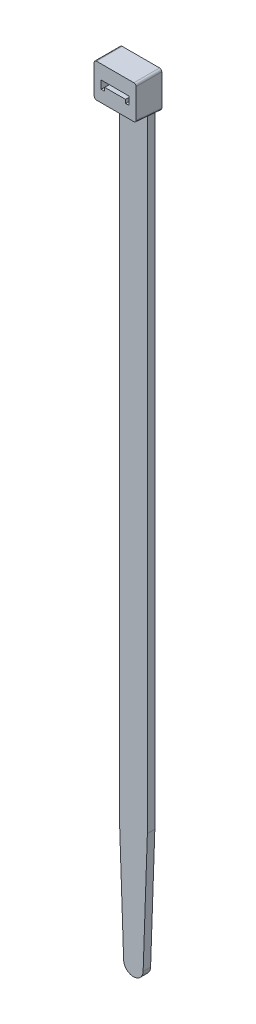
from build123d import *

# Parameters (mm, degrees)
BOSS_EXTRUDE1_DEPTH = 2.032
BOSS_EXTRUDE2_DEPTH = 5.7
CUT_EXTRUDE1_DEPTH  = 7
FILLET1_R           = 0.6


with BuildPart() as part:
    # Sketch1 → Boss-Extrude1 (new body)
    with BuildSketch(Plane.XY):
        with BuildLine():
            Line((3.81, 0), (3.81, -180.234))
            Line((3.81, -180.234), (2.654016147, -213.337046398))
            ThreePointArc((2.654016147, -213.337046398), (1.844758309, -215.154669263), (0, -215.9))
            Line((0, -215.9), (0, 0))
            Line((0, 0), (3.81, 0))
        make_face()
    extrude(amount=BOSS_EXTRUDE1_DEPTH)

    # Sketch5 → Boss-Extrude2 (add)
    with BuildSketch(Plane.ZY):
        Polygon((0, 0), (7, 0), (7, -9.187579355), (0, -9.8), align=None)
    extrude(amount=-BOSS_EXTRUDE2_DEPTH)

    # Sketch4 → Cut-Extrude1 (cut)
    with BuildSketch(Plane.XY.offset(7)):
        Polygon((0, -3.8), (3.8, -3.8), (3.8, -6), (2.85, -6), (2.85, -5.05), (0, -5.05), align=None)
    extrude(amount=-CUT_EXTRUDE1_DEPTH, mode=Mode.SUBTRACT)

    # Fillet1
    fillet1_edges = [part.edges().sort_by_distance(p)[0] for p in [
        (5.7, 0, 3.5),
        (5.7, -9.493789678, 3.5),
    ]]
    fillet(fillet1_edges, radius=FILLET1_R)

    # Mirror1: part across plane


with BuildPart() as part_1:
    add(part.part)
    add(part.part.mirror(Plane(origin=(0, -215.9, 2.032), x_dir=(0, 0, 1), z_dir=(1, 0, 0))))


solid = part_1.part
